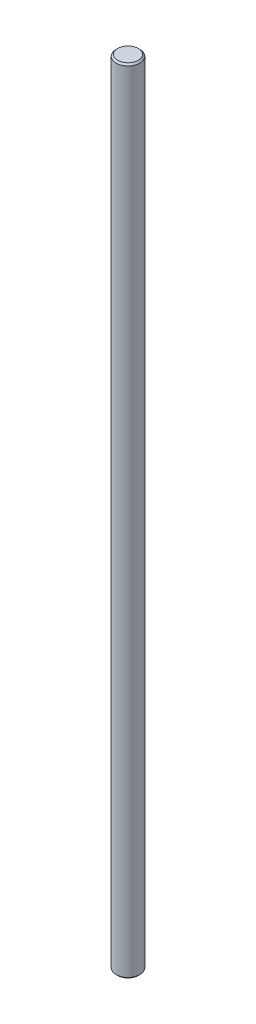
from build123d import *

# Parameters (mm, degrees)
SKETCH1_R           = 1.5
BOSS_EXTRUDE1_DEPTH = 100
CHAMFER1_SIZE       = 0.2


with BuildPart() as part:
    # Sketch1 → Boss-Extrude1 (new body)
    with BuildSketch(Plane(origin=(0, 0, 0), x_dir=(1, 0, 0), z_dir=(0, 1, 0))):
        Circle(SKETCH1_R)
    extrude(amount=BOSS_EXTRUDE1_DEPTH)

    # Chamfer1
    chamfer1_edges = [part.edges().sort_by_distance(p)[0] for p in [
        (-1.5, 0, 0),
        (-1.5, 100, 0),
    ]]
    chamfer(chamfer1_edges, length=CHAMFER1_SIZE)


solid = part.part
